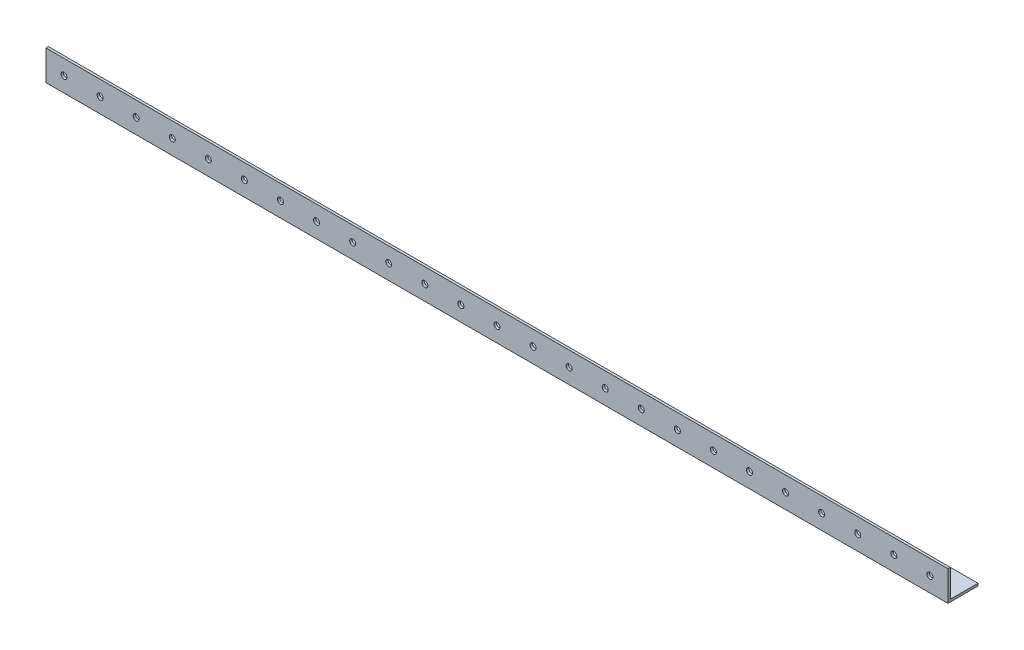
from build123d import *

# Parameters (mm, degrees)
EXTRUDE_1_DEPTH     = 1500
SKETCH_2_R          = 5
CUT_EXTRUDE_1_DEPTH = 51
SKETCH_3_R          = 5
CUT_EXTRUDE_2_DEPTH = 51


with BuildPart() as part:
    # Эскиз1 → Вытянуть-Тонкостенный1 (new body)
    with BuildSketch(Plane(origin=(0, 0, 0), x_dir=(0, 0, -1), z_dir=(1, 0, 0))):
        Polygon((50, 0), (0, 0), (0, 50), (4, 50), (4, 4), (50, 4), align=None)
    extrude(amount=EXTRUDE_1_DEPTH)

    # Эскиз2 → Вырез-Вытянуть1 (cut, through all)
    with BuildSketch(Plane.XY):
        with Locations((30, 25)):
            Circle(SKETCH_2_R)
        with Locations((90, 25)):
            Circle(SKETCH_2_R)
        with Locations((150, 25)):
            Circle(SKETCH_2_R)
        with Locations((210, 25)):
            Circle(SKETCH_2_R)
        with Locations((270, 25)):
            Circle(SKETCH_2_R)
        with Locations((330, 25)):
            Circle(SKETCH_2_R)
        with Locations((390, 25)):
            Circle(SKETCH_2_R)
        with Locations((450, 25)):
            Circle(SKETCH_2_R)
        with Locations((510, 25)):
            Circle(SKETCH_2_R)
        with Locations((570, 25)):
            Circle(SKETCH_2_R)
        with Locations((630, 25)):
            Circle(SKETCH_2_R)
        with Locations((690, 25)):
            Circle(SKETCH_2_R)
        with Locations((750, 25)):
            Circle(SKETCH_2_R)
        with Locations((810, 25)):
            Circle(SKETCH_2_R)
        with Locations((870, 25)):
            Circle(SKETCH_2_R)
        with Locations((930, 25)):
            Circle(SKETCH_2_R)
        with Locations((990, 25)):
            Circle(SKETCH_2_R)
        with Locations((1050, 25)):
            Circle(SKETCH_2_R)
        with Locations((1110, 25)):
            Circle(SKETCH_2_R)
        with Locations((1170, 25)):
            Circle(SKETCH_2_R)
        with Locations((1230, 25)):
            Circle(SKETCH_2_R)
        with Locations((1290, 25)):
            Circle(SKETCH_2_R)
        with Locations((1350, 25)):
            Circle(SKETCH_2_R)
        with Locations((1410, 25)):
            Circle(SKETCH_2_R)
        with Locations((1470, 25)):
            Circle(SKETCH_2_R)
    extrude(amount=-CUT_EXTRUDE_1_DEPTH, mode=Mode.SUBTRACT)

    # Эскиз3 → Вырез-Вытянуть2 (cut, through all)
    with BuildSketch(Plane.XZ):
        with Locations((30, -25)):
            Circle(SKETCH_3_R)
        with Locations((90, -25)):
            Circle(SKETCH_3_R)
        with Locations((150, -25)):
            Circle(SKETCH_3_R)
        with Locations((210, -25)):
            Circle(SKETCH_3_R)
        with Locations((270, -25)):
            Circle(SKETCH_3_R)
        with Locations((330, -25)):
            Circle(SKETCH_3_R)
        with Locations((390, -25)):
            Circle(SKETCH_3_R)
        with Locations((450, -25)):
            Circle(SKETCH_3_R)
        with Locations((510, -25)):
            Circle(SKETCH_3_R)
        with Locations((570, -25)):
            Circle(SKETCH_3_R)
        with Locations((630, -25)):
            Circle(SKETCH_3_R)
        with Locations((690, -25)):
            Circle(SKETCH_3_R)
        with Locations((750, -25)):
            Circle(SKETCH_3_R)
        with Locations((810, -25)):
            Circle(SKETCH_3_R)
        with Locations((870, -25)):
            Circle(SKETCH_3_R)
        with Locations((930, -25)):
            Circle(SKETCH_3_R)
        with Locations((990, -25)):
            Circle(SKETCH_3_R)
        with Locations((1050, -25)):
            Circle(SKETCH_3_R)
        with Locations((1110, -25)):
            Circle(SKETCH_3_R)
        with Locations((1170, -25)):
            Circle(SKETCH_3_R)
        with Locations((1230, -25)):
            Circle(SKETCH_3_R)
        with Locations((1290, -25)):
            Circle(SKETCH_3_R)
        with Locations((1350, -25)):
            Circle(SKETCH_3_R)
        with Locations((1410, -25)):
            Circle(SKETCH_3_R)
        with Locations((1470, -25)):
            Circle(SKETCH_3_R)
    extrude(amount=-CUT_EXTRUDE_2_DEPTH, mode=Mode.SUBTRACT)


solid = part.part
